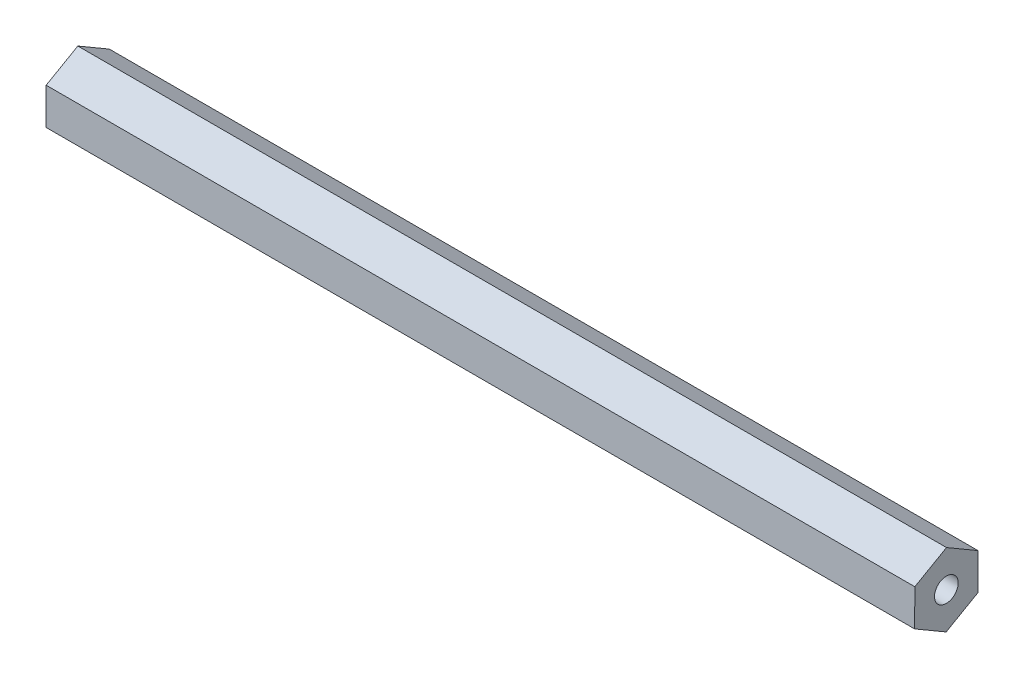
from build123d import *

# Parameters (mm, degrees)
SKETCH1_R           = 2.38125
BOSS_EXTRUDE1_DEPTH = 174.625


with BuildPart() as part:
    # Sketch1 → Boss-Extrude1 (new body)
    with BuildSketch(Plane(origin=(0, 0, 0), x_dir=(0, 0, -1), z_dir=(1, 0, 0))):
        Polygon((6.36626123, 3.63786356), (0.032648357, 7.332275733), (-6.333612874, 3.694412172), (-6.36626123, -3.63786356), (-0.032648357, -7.332275733), (6.333612874, -3.694412172), align=None)
        Circle(SKETCH1_R, mode=Mode.SUBTRACT)
    extrude(amount=BOSS_EXTRUDE1_DEPTH)


solid = part.part
